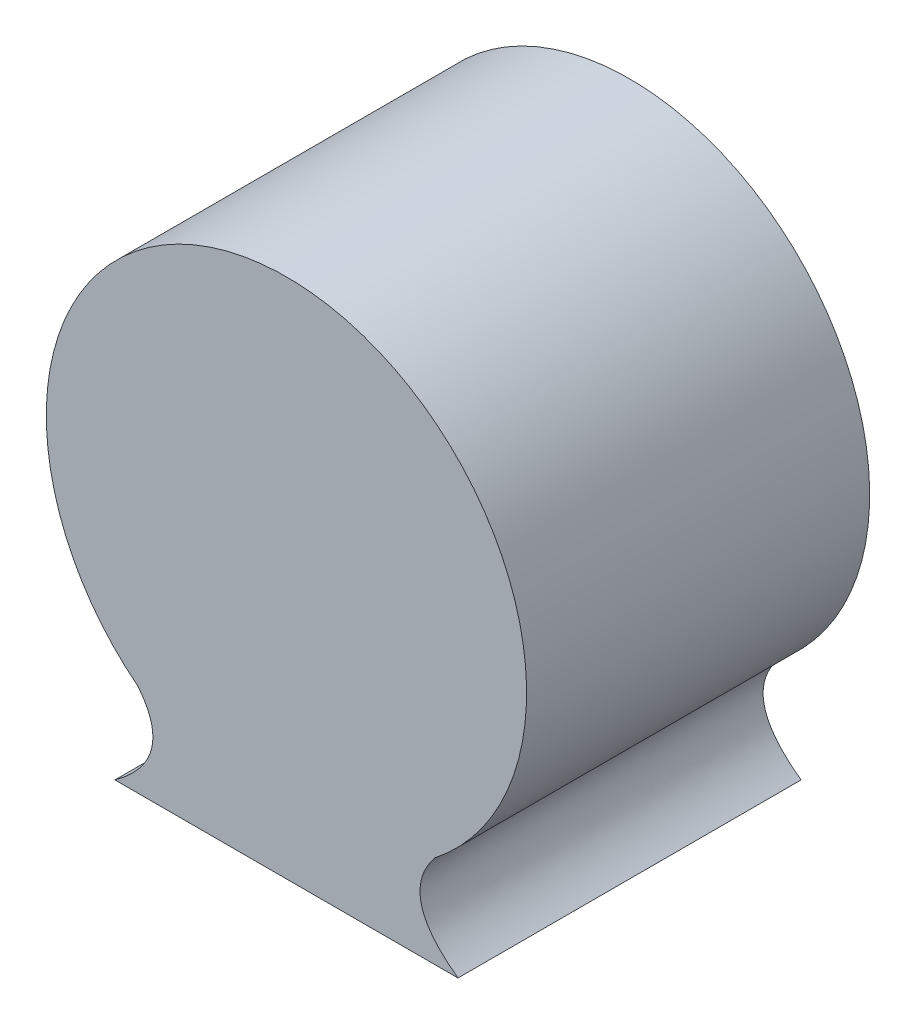
from build123d import *

# Parameters (mm, degrees)
DODANIE_WYCI_GNI_CIE1_DEPTH = 50


with BuildPart() as part:
    # Szkic1 → Dodanie-wyciągnięcie1 (new body)
    with BuildSketch(Plane.XY):
        with BuildLine():
            Line((25, -41), (-25, -41))
            add(Edge.make_bspline(
                [(-25, -41), (-16.009754391, -34.51349833), (-21.626701749, -27.518825765)],
                knots=[0, 0, 0, 1, 1, 1], degree=2))
            ThreePointArc((-21.626701749, -27.518825765), (0, 35), (21.626701749, -27.518825765))
            add(Edge.make_bspline(
                [(25, -41), (16.009754391, -34.51349833), (21.626701749, -27.518825765)],
                knots=[0, 0, 0, 1, 1, 1], degree=2))
        make_face()
    extrude(amount=DODANIE_WYCI_GNI_CIE1_DEPTH)


solid = part.part
